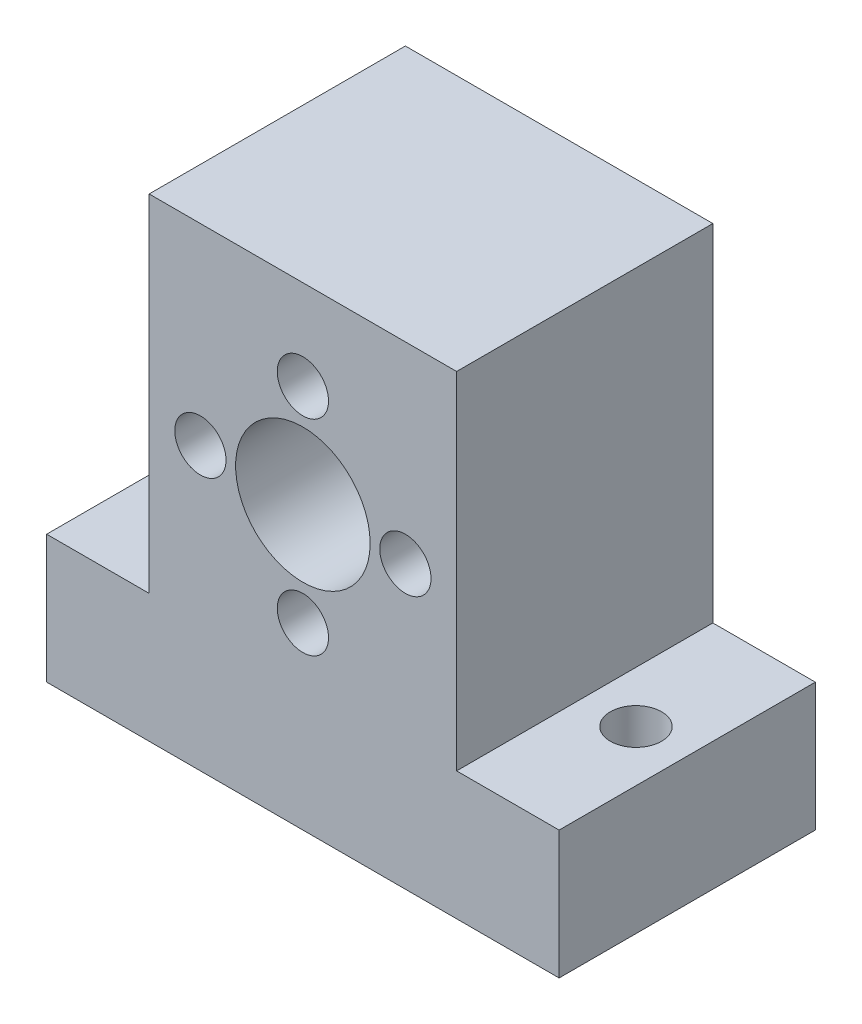
from build123d import *

# Parameters (mm, degrees)
SKETCH1_W           = 40
SKETCH1_H           = 37
SKETCH1_R           = 5.25
SKETCH1_R_2         = 2
BOSS_EXTRUDE1_DEPTH = 20
SKETCH2_R           = 2
CUT_EXTRUDE1_DEPTH  = 38
SKETCH3_W           = 8
SKETCH3_H           = 27
CUT_EXTRUDE2_DEPTH  = 21


with BuildPart() as part:
    # Sketch1 → Boss-Extrude1 (new body)
    with BuildSketch(Plane.XY):
        with Locations((0, -3.5)):
            Rectangle(SKETCH1_W, SKETCH1_H)
        Circle(SKETCH1_R, mode=Mode.SUBTRACT)
        with Locations((0, 8)):
            Circle(SKETCH1_R_2, mode=Mode.SUBTRACT)
        with Locations((8, 0)):
            Circle(SKETCH1_R_2, mode=Mode.SUBTRACT)
        with Locations((0, -8)):
            Circle(SKETCH1_R_2, mode=Mode.SUBTRACT)
        with Locations((-8, 0)):
            Circle(SKETCH1_R_2, mode=Mode.SUBTRACT)
    extrude(amount=BOSS_EXTRUDE1_DEPTH)

    # Sketch2 → Cut-Extrude1 (cut, through all)
    with BuildSketch(Plane(origin=(0, 15, 0), x_dir=(1, 0, 0), z_dir=(0, 1, 0))):
        with Locations((-16, -10)):
            Circle(SKETCH2_R)
        with Locations((16, -10)):
            Circle(SKETCH2_R)
    extrude(amount=-CUT_EXTRUDE1_DEPTH, mode=Mode.SUBTRACT)

    # Sketch3 → Cut-Extrude2 (cut, through all)
    with BuildSketch(Plane(origin=(0, 0, 0), x_dir=(-1, 0, 0), z_dir=(0, 0, -1))):
        with Locations((16, 1.5)):
            Rectangle(SKETCH3_W, SKETCH3_H)
        with Locations((-16, 1.5)):
            Rectangle(SKETCH3_W, SKETCH3_H)
    extrude(amount=-CUT_EXTRUDE2_DEPTH, mode=Mode.SUBTRACT)


solid = part.part
